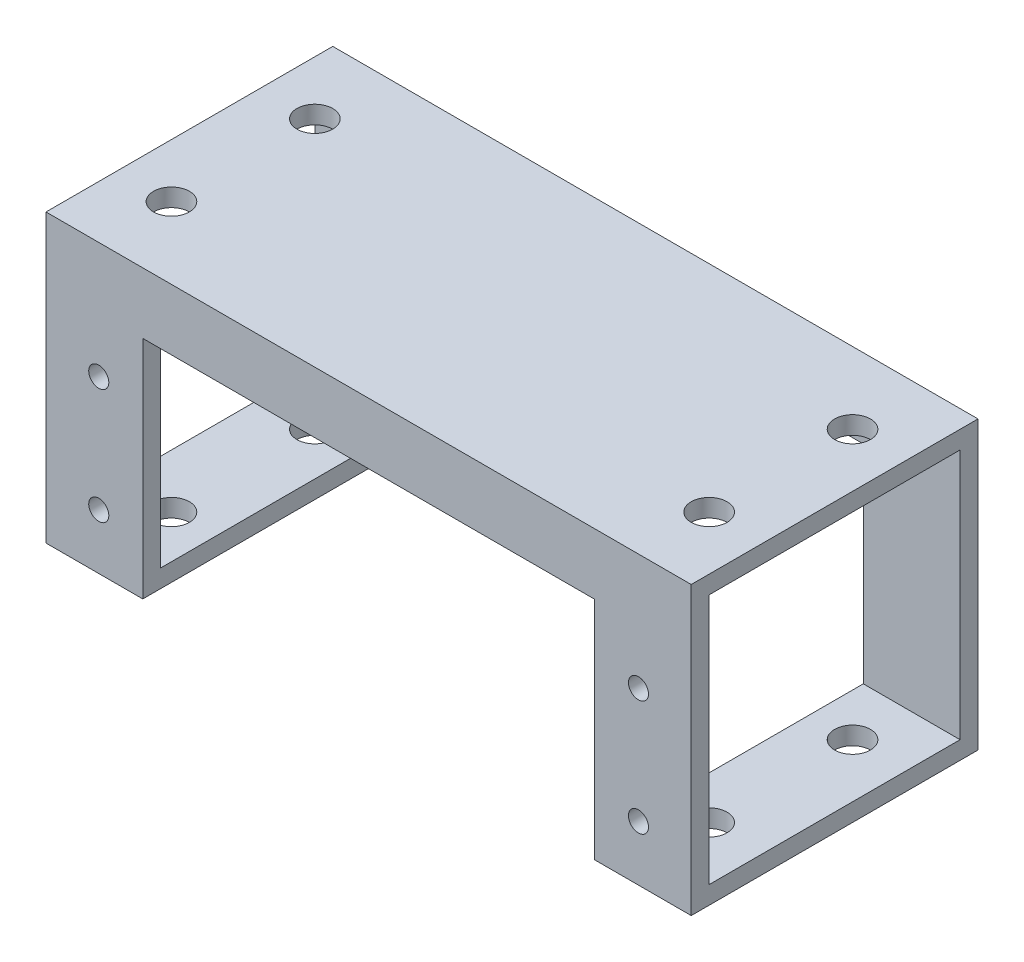
from build123d import *

# Parameters (mm, degrees)
SKETCH1_W          = 25.4
SKETCH1_H          = 25.4
SKETCH1_W_2        = 22.225
SKETCH1_H_2        = 22.225
EXTRUDE1_DEPTH     = 57.15
CUT_EXTRUDE1_REACH = 27.4
SKETCH2_W          = 40.005
SKETCH2_H          = 19.9898
CUT_EXTRUDE2_REACH = 27.4
SKETCH3_R          = 0.889
SKETCH4_R          = 1.5875
CUT_EXTRUDE3_DEPTH = 25.4


with BuildPart() as part:
    # Sketch1 → Extrude1 (new body)
    with BuildSketch(Plane(origin=(0, 0, 0), x_dir=(0, 0, -1), z_dir=(1, 0, 0))):
        with Locations((12.7, 12.7)):
            Rectangle(SKETCH1_W, SKETCH1_H)
        with Locations((12.7, 12.7)):
            Rectangle(SKETCH1_W_2, SKETCH1_H_2, mode=Mode.SUBTRACT)
    extrude(amount=EXTRUDE1_DEPTH)

    # Sketch2 → Cut-Extrude1 (cut, up to next)
    with BuildSketch(Plane.XY, mode=Mode.PRIVATE) as cut_extrude1_sk1:
        with Locations((28.575, 9.9949)):
            Rectangle(SKETCH2_W, SKETCH2_H)
    cut_extrude1_tool1 = extrude(cut_extrude1_sk1.sketch, amount=-CUT_EXTRUDE1_REACH, mode=Mode.PRIVATE) & part.part
    add(cut_extrude1_tool1.solids().sort_by_distance((28.575, 9.9949, 0))[0], mode=Mode.SUBTRACT)

    # Sketch3 → Cut-Extrude2 (cut, up to next)
    with BuildSketch(Plane.XY, mode=Mode.PRIVATE) as cut_extrude2_sk1:
        with Locations((4.6736, 15.1003)):
            Circle(SKETCH3_R)
    cut_extrude2_tool1 = extrude(cut_extrude2_sk1.sketch, amount=-CUT_EXTRUDE2_REACH, mode=Mode.PRIVATE) & part.part
    add(cut_extrude2_tool1.solids().sort_by_distance((4.6736, 15.1003, 0))[0], mode=Mode.SUBTRACT)
    # Sketch3 → Cut-Extrude2 (cut, up to next)
    with BuildSketch(Plane.XY, mode=Mode.PRIVATE) as cut_extrude2_sk2:
        with Locations((4.6736, 4.8895)):
            Circle(SKETCH3_R)
    cut_extrude2_tool2 = extrude(cut_extrude2_sk2.sketch, amount=-CUT_EXTRUDE2_REACH, mode=Mode.PRIVATE) & part.part
    add(cut_extrude2_tool2.solids().sort_by_distance((4.6736, 4.8895, 0))[0], mode=Mode.SUBTRACT)
    # Sketch3 → Cut-Extrude2 (cut, up to next)
    with BuildSketch(Plane.XY, mode=Mode.PRIVATE) as cut_extrude2_sk3:
        with Locations((52.4764, 15.1003)):
            Circle(SKETCH3_R)
    cut_extrude2_tool3 = extrude(cut_extrude2_sk3.sketch, amount=-CUT_EXTRUDE2_REACH, mode=Mode.PRIVATE) & part.part
    add(cut_extrude2_tool3.solids().sort_by_distance((52.4764, 15.1003, 0))[0], mode=Mode.SUBTRACT)
    # Sketch3 → Cut-Extrude2 (cut, up to next)
    with BuildSketch(Plane.XY, mode=Mode.PRIVATE) as cut_extrude2_sk4:
        with Locations((52.4764, 4.8895)):
            Circle(SKETCH3_R)
    cut_extrude2_tool4 = extrude(cut_extrude2_sk4.sketch, amount=-CUT_EXTRUDE2_REACH, mode=Mode.PRIVATE) & part.part
    add(cut_extrude2_tool4.solids().sort_by_distance((52.4764, 4.8895, 0))[0], mode=Mode.SUBTRACT)

    # Sketch4 → Cut-Extrude3 (cut)
    with BuildSketch(Plane(origin=(0, 25.4, 0), x_dir=(1, 0, 0), z_dir=(0, 1, 0))):
        with Locations(Location((4.7625, 19.05, 0), (0, 0, 270))):  # turned: the seam where the file's is
            Circle(SKETCH4_R)
        with Locations(Location((4.7625, 6.35, 0), (0, 0, 270))):  # turned: the seam where the file's is
            Circle(SKETCH4_R)
        with Locations(Location((52.3875, 19.05, 0), (0, 0, 270))):  # turned: the seam where the file's is
            Circle(SKETCH4_R)
        with Locations(Location((52.3875, 6.35, 0), (0, 0, 270))):  # turned: the seam where the file's is
            Circle(SKETCH4_R)
    extrude(amount=-CUT_EXTRUDE3_DEPTH, mode=Mode.SUBTRACT)


solid = part.part
